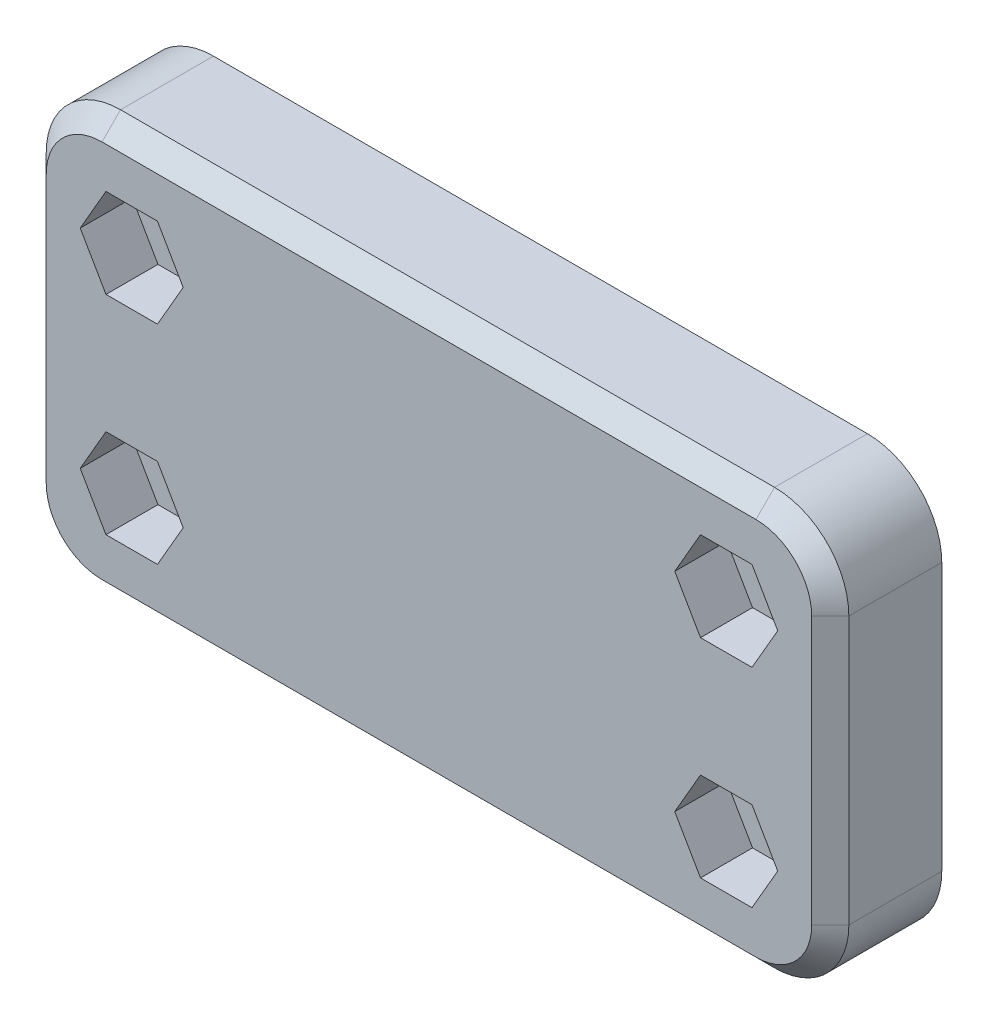
from build123d import *

# Parameters (mm, degrees)
BASE_W              = 54
BASE_H              = 28
BASE_R              = 1.55
BOSS_EXTRUDE1_DEPTH = 4
BOSS_EXTRUDE2_START = 4
BASE_3_W            = 54
BASE_3_H            = 28
BOSS_EXTRUDE2_DEPTH = 3.5
FILLET1_R           = 5
CHAMFER1_SIZE       = 1.25


with BuildPart() as part:
    # Base → Boss-Extrude1 (new body)
    with BuildSketch(Plane.XY):
        Rectangle(BASE_W, BASE_H)
        with Locations((-20, 7)):
            Circle(BASE_R, mode=Mode.SUBTRACT)
        with Locations((20, 7)):
            Circle(BASE_R, mode=Mode.SUBTRACT)
        with Locations((20, -7)):
            Circle(BASE_R, mode=Mode.SUBTRACT)
        with Locations((-20, -7)):
            Circle(BASE_R, mode=Mode.SUBTRACT)
    extrude(amount=BOSS_EXTRUDE1_DEPTH)

    # Base_3 → Boss-Extrude2 (add)
    with BuildSketch(Plane.XY.offset(BOSS_EXTRUDE2_START)):
        Rectangle(BASE_3_W, BASE_3_H)
        Polygon((-21.732050808, -10), (-18.267949192, -10), (-16.535898385, -7), (-18.267949192, -4), (-21.732050808, -4), (-23.464101615, -7), align=None, mode=Mode.SUBTRACT)
        Polygon((21.732050808, -10), (23.464101615, -7), (21.732050808, -4), (18.267949192, -4), (16.535898385, -7), (18.267949192, -10), align=None, mode=Mode.SUBTRACT)
        Polygon((21.732050808, 4), (23.464101615, 7), (21.732050808, 10), (18.267949192, 10), (16.535898385, 7), (18.267949192, 4), align=None, mode=Mode.SUBTRACT)
        Polygon((-18.267949192, 4), (-16.535898385, 7), (-18.267949192, 10), (-21.732050808, 10), (-23.464101615, 7), (-21.732050808, 4), align=None, mode=Mode.SUBTRACT)
    extrude(amount=BOSS_EXTRUDE2_DEPTH)

    # Fillet1
    fillet1_edges = [part.edges().sort_by_distance(p)[0] for p in [
        (27, 14, 3.75),
        (27, -14, 3.75),
        (-27, -14, 3.75),
        (-27, 14, 3.75),
    ]]
    fillet(fillet1_edges, radius=FILLET1_R)

    # Chamfer1
    chamfer1_edges = [part.edges().sort_by_distance(p)[0] for p in [
        (-27, 0, 7.5),
        (0, 14, 7.5),
        (0, -14, 7.5),
        (27, 0, 7.5),
        (-25.535533906, -12.535533906, 7.5),
        (25.535533906, -12.535533906, 7.5),
        (25.535533906, 12.535533906, 7.5),
        (-25.535533906, 12.535533906, 7.5),
    ]]
    chamfer(chamfer1_edges, length=CHAMFER1_SIZE)


solid = part.part
